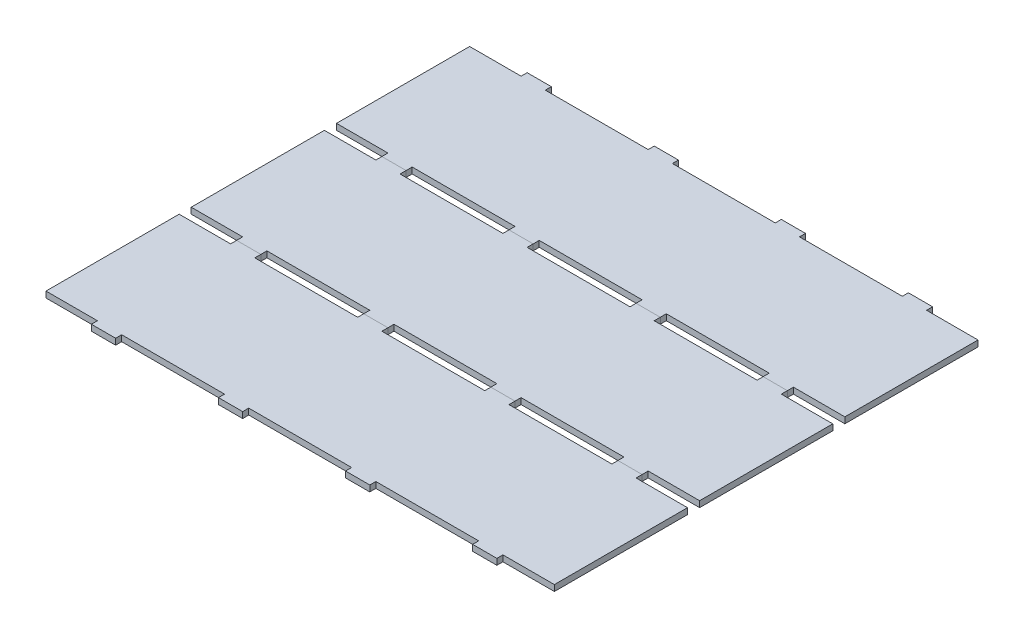
from build123d import *

# Parameters (mm, degrees)
SKETCH1_W               = 533.4
SKETCH1_H               = 152.4
BOSS_EXTRUDE1_DEPTH     = 6.35
SKETCH2_W               = 107.95
SKETCH2_H               = 6.35
CUT_EXTRUDE2_DEPTH      = 7.35
LPATTERN1_COUNT         = 3
LPATTERN1_PITCH         = 133.35
LPATTERN1_COL_COUNT     = 3
LPATTERN1_COL_PITCH     = 133.35
MIRROR2_COPY_1_SKETCH_W = 107.95
MIRROR2_COPY_1_SKETCH_H = 6.35
MIRROR2_COPY_1_DEPTH    = 7.35
MIRROR2_COPY_2_SKETCH_W = 107.95
MIRROR2_COPY_2_SKETCH_H = 6.35
MIRROR2_COPY_2_DEPTH    = 7.35
MIRROR2_COPY_3_SKETCH_W = 107.95
MIRROR2_COPY_3_SKETCH_H = 6.35
MIRROR2_COPY_3_DEPTH    = 7.35
MIRROR2_COPY_4_SKETCH_W = 107.95
MIRROR2_COPY_4_SKETCH_H = 6.35
MIRROR2_COPY_4_DEPTH    = 7.35
LPATTERN2_COUNT         = 3
LPATTERN2_PITCH         = 152.4


with BuildPart() as part:
    # Sketch1 → Boss-Extrude1 (new body)
    with BuildSketch(Plane(origin=(0, 0, 0), x_dir=(1, 0, 0), z_dir=(0, 1, 0))):
        Rectangle(SKETCH1_W, SKETCH1_H)
    extrude(amount=BOSS_EXTRUDE1_DEPTH)

    # Sketch2 → Cut-Extrude2 (cut, through all)
    with BuildSketch(Plane(origin=(0, 6.35, 0), x_dir=(1, 0, 0), z_dir=(0, 1, 0))):
        with Locations((0, -73.025)):
            Rectangle(SKETCH2_W, SKETCH2_H)
    cut_extrude2 = extrude(amount=-CUT_EXTRUDE2_DEPTH, mode=Mode.SUBTRACT)

    # LPattern1: Cut-Extrude2 ×3
    with Locations(*[(-i * LPATTERN1_PITCH, 0, 0) for i in range(1, LPATTERN1_COUNT)]):
        add(cut_extrude2, mode=Mode.SUBTRACT)

    # LPattern1 col: Cut-Extrude2 ×3
    with Locations(*[(i * LPATTERN1_COL_PITCH, 0, 0) for i in range(1, LPATTERN1_COL_COUNT)]):
        add(cut_extrude2, mode=Mode.SUBTRACT)

    # Mirror2: Cut-Extrude2 across plane
    add(cut_extrude2.mirror(Plane.XY), mode=Mode.SUBTRACT)

    # Mirror2 copy 1 sketch → Mirror2 copy 1 (cut, through all)
    with BuildSketch(Plane(origin=(-133.35, 6.35, 0), x_dir=(1, 0, 0), z_dir=(0, 1, 0))):
        with Locations((0, 73.025)):
            Rectangle(MIRROR2_COPY_1_SKETCH_W, MIRROR2_COPY_1_SKETCH_H)
    extrude(amount=-MIRROR2_COPY_1_DEPTH, mode=Mode.SUBTRACT)

    # Mirror2 copy 2 sketch → Mirror2 copy 2 (cut, through all)
    with BuildSketch(Plane(origin=(-266.7, 6.35, 0), x_dir=(1, 0, 0), z_dir=(0, 1, 0))):
        with Locations((0, 73.025)):
            Rectangle(MIRROR2_COPY_2_SKETCH_W, MIRROR2_COPY_2_SKETCH_H)
    extrude(amount=-MIRROR2_COPY_2_DEPTH, mode=Mode.SUBTRACT)

    # Mirror2 copy 3 sketch → Mirror2 copy 3 (cut, through all)
    with BuildSketch(Plane(origin=(133.35, 6.35, 0), x_dir=(1, 0, 0), z_dir=(0, 1, 0))):
        with Locations((0, 73.025)):
            Rectangle(MIRROR2_COPY_3_SKETCH_W, MIRROR2_COPY_3_SKETCH_H)
    extrude(amount=-MIRROR2_COPY_3_DEPTH, mode=Mode.SUBTRACT)

    # Mirror2 copy 4 sketch → Mirror2 copy 4 (cut, through all)
    with BuildSketch(Plane(origin=(266.7, 6.35, 0), x_dir=(1, 0, 0), z_dir=(0, 1, 0))):
        with Locations((0, 73.025)):
            Rectangle(MIRROR2_COPY_4_SKETCH_W, MIRROR2_COPY_4_SKETCH_H)
    extrude(amount=-MIRROR2_COPY_4_DEPTH, mode=Mode.SUBTRACT)


with BuildPart() as lpattern2_1:
    # LPattern2: pattern copy
    add(part.part.moved(Location(Vector(0, 0, 1) * (1 * LPATTERN2_PITCH))))


with BuildPart() as lpattern2_2:
    # LPattern2: pattern copy
    add(part.part.moved(Location(Vector(0, 0, 1) * (2 * LPATTERN2_PITCH))))


solid = Compound([part.part, lpattern2_1.part, lpattern2_2.part])
